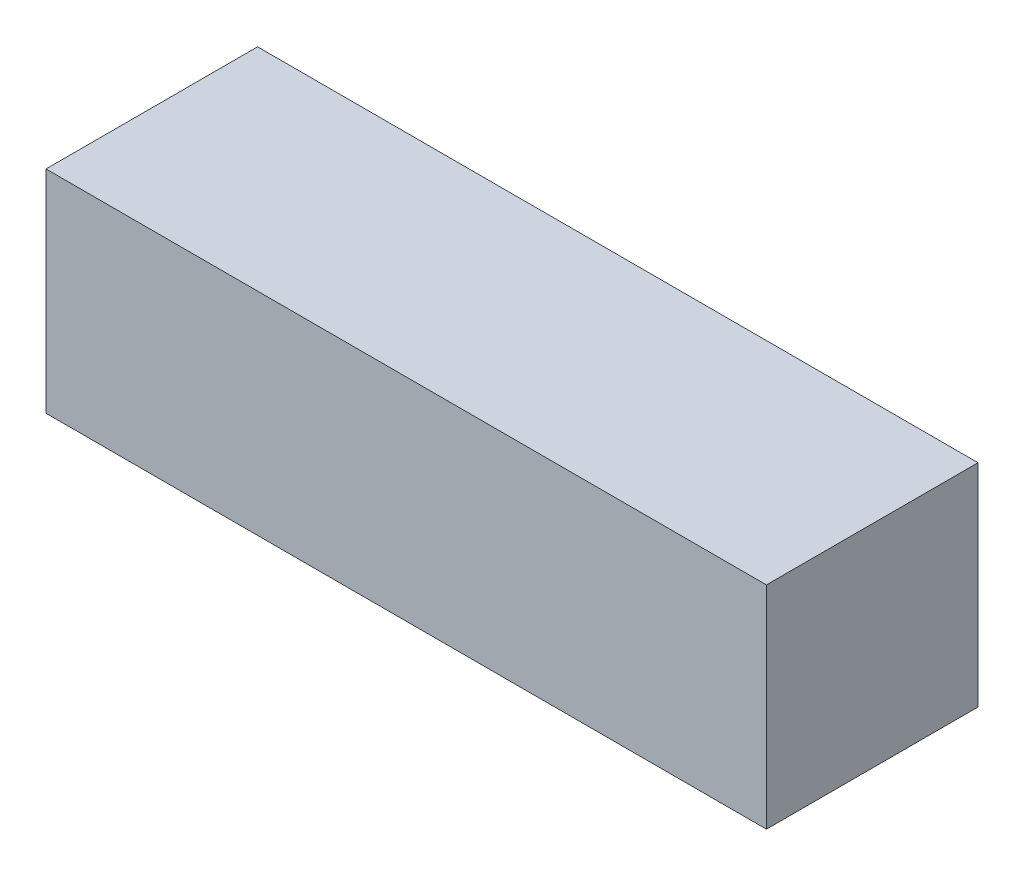
from build123d import *

# Parameters (mm, degrees)
SKETCH1_W           = 340.5
SKETCH1_H           = 100
BOSS_EXTRUDE1_DEPTH = 100


with BuildPart() as part:
    # Sketch1 → Boss-Extrude1 (new body)
    with BuildSketch(Plane(origin=(0, 0, 0), x_dir=(1, 0, 0), z_dir=(0, 1, 0))):
        Rectangle(SKETCH1_W, SKETCH1_H)
    extrude(amount=BOSS_EXTRUDE1_DEPTH)


solid = part.part
